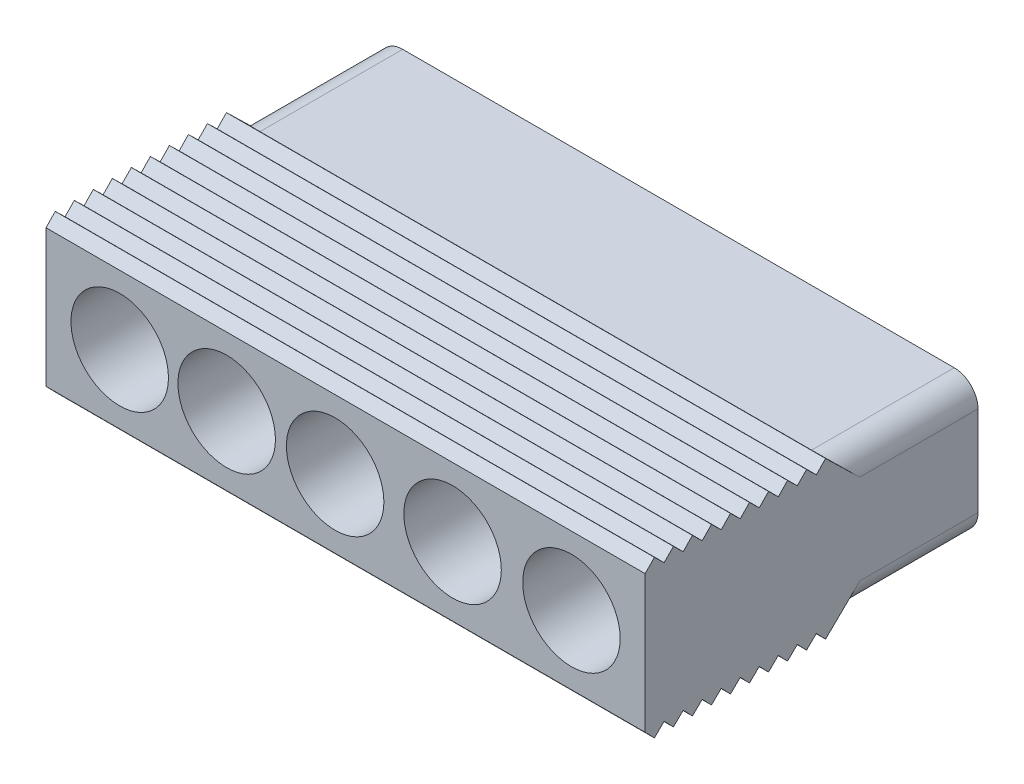
from build123d import *

# Parameters (mm, degrees)
SKETCH1_W            = 25.2
SKETCH1_H            = 5.78
BOSS_EXTRUDE1_DEPTH  = 14
SKETCH2_R            = 2.05
CUT_EXTRUDE1_DEPTH   = 13.1
CUT_EXTRUDE2_REACH   = 16
SKETCH4_R            = 1.775
BOSS_EXTRUDE2_DEPTH  = 0.3
BOSS_EXTRUDE3_DEPTH  = 25.2
LPATTERN1_COUNT      = 10
LPATTERN1_PITCH      = 0.8
MIRROR1_COPY_1_DEPTH = 25.2
MIRROR1_COPY_2_DEPTH = 25.2
MIRROR1_COPY_3_DEPTH = 25.2
MIRROR1_COPY_4_DEPTH = 25.2
MIRROR1_COPY_5_DEPTH = 25.2
MIRROR1_COPY_6_DEPTH = 25.2
MIRROR1_COPY_7_DEPTH = 25.2
MIRROR1_COPY_8_DEPTH = 25.2
MIRROR1_COPY_9_DEPTH = 25.2
FILLET1_R            = 1


with BuildPart() as part:
    # Sketch1 → Boss-Extrude1 (new body)
    with BuildSketch(Plane.XY):
        with Locations((-2.28, 0.689500873)):
            Rectangle(SKETCH1_W, SKETCH1_H)
    extrude(amount=BOSS_EXTRUDE1_DEPTH)

    # Sketch2 → Cut-Extrude1 (cut)
    with BuildSketch(Plane.XY.offset(14)):
        with Locations((-11.78, 0.689500873)):
            Circle(SKETCH2_R)
        with Locations((-7.28, 0.689500873)):
            Circle(SKETCH2_R)
        with Locations((-2.71821789, 0.689500873)):
            Circle(SKETCH2_R)
        with Locations((2.22, 0.689500873)):
            Circle(SKETCH2_R)
        with Locations((7.22, 0.689500873)):
            Circle(SKETCH2_R)
    extrude(amount=-CUT_EXTRUDE1_DEPTH, mode=Mode.SUBTRACT)

    # Sketch4 → Cut-Extrude2 (cut, up to next)
    with BuildSketch(Plane.XY.offset(14), mode=Mode.PRIVATE) as cut_extrude2_sk1:
        with Locations((7.22, 0.689500873)):
            Circle(SKETCH4_R)
    cut_extrude2_tool1 = extrude(cut_extrude2_sk1.sketch, amount=-CUT_EXTRUDE2_REACH, mode=Mode.PRIVATE) & part.part
    add(cut_extrude2_tool1.solids().sort_by_distance((7.22, 0.689501, 14))[0], mode=Mode.SUBTRACT)
    # Sketch4 → Cut-Extrude2 (cut, up to next)
    with BuildSketch(Plane.XY.offset(14), mode=Mode.PRIVATE) as cut_extrude2_sk2:
        with Locations((2.22, 0.689500873)):
            Circle(SKETCH4_R)
    cut_extrude2_tool2 = extrude(cut_extrude2_sk2.sketch, amount=-CUT_EXTRUDE2_REACH, mode=Mode.PRIVATE) & part.part
    add(cut_extrude2_tool2.solids().sort_by_distance((2.22, 0.689501, 14))[0], mode=Mode.SUBTRACT)
    # Sketch4 → Cut-Extrude2 (cut, up to next)
    with BuildSketch(Plane.XY.offset(14), mode=Mode.PRIVATE) as cut_extrude2_sk3:
        with Locations((-2.71821789, 0.689500873)):
            Circle(SKETCH4_R)
    cut_extrude2_tool3 = extrude(cut_extrude2_sk3.sketch, amount=-CUT_EXTRUDE2_REACH, mode=Mode.PRIVATE) & part.part
    add(cut_extrude2_tool3.solids().sort_by_distance((-2.718218, 0.689501, 14))[0], mode=Mode.SUBTRACT)
    # Sketch4 → Cut-Extrude2 (cut, up to next)
    with BuildSketch(Plane.XY.offset(14), mode=Mode.PRIVATE) as cut_extrude2_sk4:
        with Locations((-7.28, 0.689500873)):
            Circle(SKETCH4_R)
    cut_extrude2_tool4 = extrude(cut_extrude2_sk4.sketch, amount=-CUT_EXTRUDE2_REACH, mode=Mode.PRIVATE) & part.part
    add(cut_extrude2_tool4.solids().sort_by_distance((-7.28, 0.689501, 14))[0], mode=Mode.SUBTRACT)
    # Sketch4 → Cut-Extrude2 (cut, up to next)
    with BuildSketch(Plane.XY.offset(14), mode=Mode.PRIVATE) as cut_extrude2_sk5:
        with Locations((-11.78, 0.689500873)):
            Circle(SKETCH4_R)
    cut_extrude2_tool5 = extrude(cut_extrude2_sk5.sketch, amount=-CUT_EXTRUDE2_REACH, mode=Mode.PRIVATE) & part.part
    add(cut_extrude2_tool5.solids().sort_by_distance((-11.78, 0.689501, 14))[0], mode=Mode.SUBTRACT)

    # Sketch5 → Boss-Extrude2 (add)
    with BuildSketch(Plane.XZ.offset(2.200499127)):
        Polygon((5.565344548, 5.115989136), (6.350966069, 5.115989136), (6.675864556, 4.226955746), (8.154499953, 4.226955746), (8.479398441, 5.115989136), (9.269650344, 5.115989136), (7.813395128, 1.263511109), (7.028545337, 1.263511109), align=None)
        Polygon((6.91124232, 3.584876074), (7.417497446, 2.201935244), (7.922209111, 3.584876074), align=None, mode=Mode.SUBTRACT)
        with BuildLine():
            Line((3.948610508, 1.263511109), (2.396660726, 1.263511109))
            add(Edge.make_bspline(
                [(2.396660726, 1.263511109), (2.359360489, 1.263729429), (2.287329461, 1.264151031), (2.182869204, 1.265393936), (2.085894226, 1.268736074), (1.996082295, 1.272305516), (1.913726837, 1.277578451), (1.838624432, 1.284664747), (1.770950602, 1.292313344), (1.690889796, 1.302991783), (1.598490479, 1.32403547), (1.493642217, 1.358610026), (1.39493855, 1.403888217), (1.301805377, 1.458499444), (1.215843087, 1.524426943), (1.137736598, 1.600819207), (1.065966282, 1.68620286), (1.003197045, 1.781249302), (0.950716627, 1.884651514), (0.91416523, 1.995502844), (0.890657802, 2.112203236), (0.887828684, 2.192044487), (0.886384384, 2.232804459)],
                knots=[0, 0, 0, 0, 0.000111904, 0.000216099, 0.000313386, 0.000402989, 0.000485741, 0.00056092, 0.00062927, 0.00069006, 0.000803147, 0.000912966, 0.001020713, 0.001128316, 0.00123621, 0.001344816, 0.001455483, 0.001570209, 0.001685827, 0.001802235, 0.001919381, 0.002041558, 0.002041558, 0.002041558, 0.002041558], degree=3))
            add(Edge.make_bspline(
                [(0.886384384, 2.232804459), (0.887809836, 2.277208782), (0.890630305, 2.36506929), (0.919383734, 2.493104477), (0.962229037, 2.616216273), (1.024423896, 2.731017678), (1.100162495, 2.837171215), (1.190790518, 2.929188126), (1.292463211, 3.009404764), (1.369247746, 3.048712406), (1.408074117, 3.068588454)],
                knots=[0, 0, 0, 0, 0.000133009, 0.000263178, 0.000391816, 0.00052301, 0.000653453, 0.000781702, 0.000909358, 0.001039933, 0.001039933, 0.001039933, 0.001039933], degree=3))
            add(Edge.make_bspline(
                [(1.408074117, 3.068588454), (1.381956565, 3.077484352), (1.330315447, 3.09507383), (1.256399133, 3.127373139), (1.187143549, 3.164830538), (1.122583472, 3.206264872), (1.062228915, 3.25197904), (1.007843199, 3.303488816), (0.956305643, 3.357863665), (0.911059666, 3.417833045), (0.870105113, 3.480528711), (0.835340819, 3.546931978), (0.805237834, 3.615445677), (0.780062151, 3.686763213), (0.762116284, 3.761362908), (0.747736937, 3.838305), (0.740380865, 3.91812275), (0.738940991, 3.97201565), (0.738212152, 3.999295285)],
                knots=[0, 0, 0, 0, 8.2748e-05, 0.000163614, 0.000241651, 0.000318716, 0.000393577, 0.000468387, 0.000543198, 0.000618059, 0.000693409, 0.000767632, 0.000842621, 0.000917792, 0.000994158, 0.001072571, 0.001152433, 0.001234295, 0.001234295, 0.001234295, 0.001234295], degree=3))
            add(Edge.make_bspline(
                [(0.738212152, 3.999295285), (0.73976637, 4.042860457), (0.742876676, 4.130043209), (0.765972078, 4.259625684), (0.804159522, 4.387219209), (0.857218311, 4.511066905), (0.922592861, 4.628646918), (1.000900249, 4.734738507), (1.089727441, 4.828747927), (1.19010147, 4.909568329), (1.302486516, 4.977663389), (1.427549661, 5.030526219), (1.564651545, 5.069882807), (1.660965442, 5.082994391), (1.710592423, 5.089750304)],
                knots=[0, 0, 0, 0, 0.000130651, 0.000261458, 0.00039355, 0.000529439, 0.000664888, 0.000796241, 0.000923975, 0.001051852, 0.001181689, 0.001316867, 0.001458067, 0.001608158, 0.001608158, 0.001608158, 0.001608158], degree=3))
            add(Edge.make_bspline(
                [(1.710592423, 5.089750304), (1.729623612, 5.091355687), (1.773311169, 5.095040968), (1.847402837, 5.099622774), (1.938502217, 5.103086109), (2.046530205, 5.107181064), (2.17181936, 5.110137741), (2.314084936, 5.112156752), (2.473569675, 5.11477703), (2.585476304, 5.115571115), (2.644386176, 5.115989136)],
                knots=[0, 0, 0, 0, 5.7295e-05, 0.000131526, 0.000222672, 0.000330783, 0.000455842, 0.00059863, 0.000757624, 0.000934357, 0.000934357, 0.000934357, 0.000934357], degree=3))
            Line((2.644386176, 5.115989136), (3.948610508, 5.115989136))
            Line((3.948610508, 5.115989136), (3.948610508, 1.263511109))
        make_face()
        with BuildLine():
            Line((3.207749349, 1.90559078), (3.207749349, 2.794624171))
            Line((3.207749349, 2.794624171), (2.671396739, 2.794624171))
            add(Edge.make_bspline(
                [(2.671396739, 2.794624171), (2.633581615, 2.794707482), (2.561551841, 2.794866171), (2.459171167, 2.793802767), (2.367843704, 2.793306322), (2.287832021, 2.791849334), (2.219152544, 2.789444763), (2.162052736, 2.787043604), (2.116202639, 2.785225649), (2.089505192, 2.782629691), (2.077936081, 2.781504755)],
                knots=[0, 0, 0, 0, 0.000113444, 0.000216087, 0.000307155, 0.00038743, 0.000456153, 0.000513308, 0.000558899, 0.000593763, 0.000593763, 0.000593763, 0.000593763], degree=3))
            add(Edge.make_bspline(
                [(2.077936081, 2.781504755), (2.04456019, 2.776503765), (1.980413775, 2.766892169), (1.890630004, 2.738291447), (1.811915304, 2.698052123), (1.745939077, 2.645887945), (1.691883166, 2.584536341), (1.654412919, 2.512195576), (1.631337039, 2.430993955), (1.6286434, 2.373677738), (1.627245543, 2.343933633)],
                knots=[0, 0, 0, 0, 0.000101123, 0.000194353, 0.000281336, 0.000364861, 0.000445303, 0.000524701, 0.00060728, 0.000696364, 0.000696364, 0.000696364, 0.000696364], degree=3))
            add(Edge.make_bspline(
                [(1.627245543, 2.343933633), (1.628182941, 2.315492455), (1.629998532, 2.260406403), (1.650981242, 2.18264882), (1.682772835, 2.112403946), (1.72902174, 2.051384951), (1.788784728, 2.000877344), (1.86067227, 1.960703649), (1.945473503, 1.93335539), (2.006502575, 1.923755594), (2.038577832, 1.918710197)],
                knots=[0, 0, 0, 0, 8.5115e-05, 0.000164853, 0.000239775, 0.000315251, 0.000392428, 0.000472932, 0.000560787, 0.000658114, 0.000658114, 0.000658114, 0.000658114], degree=3))
            add(Edge.make_bspline(
                [(2.038577832, 1.918710197), (2.05117635, 1.917581798), (2.080961504, 1.914914061), (2.132728511, 1.913181302), (2.198829789, 1.910723547), (2.279088615, 1.908382815), (2.373760856, 1.906891819), (2.482323129, 1.906416201), (2.605283506, 1.905343918), (2.69197592, 1.905505457), (2.737765551, 1.90559078)],
                knots=[0, 0, 0, 0, 3.7941e-05, 8.9698e-05, 0.000155336, 0.000236401, 0.000330565, 0.000439381, 0.000562089, 0.000699457, 0.000699457, 0.000699457, 0.000699457], degree=3))
            Line((2.737765551, 1.90559078), (3.207749349, 1.90559078))
        make_face(mode=Mode.SUBTRACT)
        with BuildLine():
            Line((3.207749349, 3.436703843), (3.207749349, 4.473909465))
            Line((3.207749349, 4.473909465), (2.451453582, 4.473909465))
            add(Edge.make_bspline(
                [(2.451453582, 4.473909465), (2.416209482, 4.474084294), (2.349318686, 4.474416107), (2.253894747, 4.472193667), (2.168709758, 4.471460847), (2.093365018, 4.467804767), (2.028256448, 4.46503898), (1.973116145, 4.461590963), (1.928374646, 4.45610762), (1.901971605, 4.451850625), (1.8904056, 4.449985824)],
                knots=[0, 0, 0, 0, 0.000105727, 0.000200662, 0.000286338, 0.00036126, 0.00042693, 0.000481858, 0.000526943, 0.000562089, 0.000562089, 0.000562089, 0.000562089], degree=3))
            add(Edge.make_bspline(
                [(1.8904056, 4.449985824), (1.861032664, 4.443789315), (1.803963338, 4.431749982), (1.724886025, 4.397188911), (1.653228117, 4.353218007), (1.591665084, 4.296574571), (1.539922296, 4.22972946), (1.504717678, 4.15059231), (1.48228265, 4.061754423), (1.48017452, 3.998928693), (1.479073311, 3.966110879)],
                knots=[0, 0, 0, 0, 8.9843e-05, 0.000174558, 0.000257424, 0.000341003, 0.000424196, 0.000509143, 0.000598985, 0.000697241, 0.000697241, 0.000697241, 0.000697241], degree=3))
            add(Edge.make_bspline(
                [(1.479073311, 3.966110879), (1.479952853, 3.937967908), (1.481664778, 3.883190901), (1.499485919, 3.804771406), (1.526105069, 3.73239646), (1.565263414, 3.667581003), (1.615417361, 3.611002612), (1.674726942, 3.561548533), (1.744534251, 3.521388895), (1.810953977, 3.494767709), (1.873882172, 3.477313392), (1.93450193, 3.467565061), (2.006954879, 3.457033596), (2.091757251, 3.45009901), (2.188468264, 3.443545881), (2.297357448, 3.440494331), (2.418502378, 3.436767827), (2.503412768, 3.436725847), (2.547919879, 3.436703843)],
                knots=[0, 0, 0, 0, 8.4292e-05, 0.000164064, 0.000240028, 0.000314806, 0.000389728, 0.00046591, 0.000545458, 0.000630296, 0.000679909, 0.000741066, 0.000814299, 0.00089954, 0.000996204, 0.001105086, 0.001226287, 0.001359798, 0.001359798, 0.001359798, 0.001359798], degree=3))
            Line((2.547919879, 3.436703843), (3.207749349, 3.436703843))
        make_face(mode=Mode.SUBTRACT)
        with BuildLine():
            add(Edge.make_bspline(
                [(-2.557807182, 1.263511109), (-2.603666, 1.264613532), (-2.692947863, 1.266759824), (-2.823016429, 1.285884832), (-2.945342558, 1.31623148), (-3.05994986, 1.360066798), (-3.167421192, 1.415546055), (-3.266244385, 1.485133496), (-3.358707652, 1.565450648), (-3.412086175, 1.62781847), (-3.439123269, 1.659408791)],
                knots=[0, 0, 0, 0, 0.000137507, 0.00026771, 0.00039349, 0.000514887, 0.00063501, 0.000755323, 0.000876708, 0.001001299, 0.001001299, 0.001001299, 0.001001299], degree=3))
            add(Edge.make_bspline(
                [(-3.439123269, 1.659408791), (-3.454589811, 1.679525698), (-3.486154311, 1.720580781), (-3.528664115, 1.786921385), (-3.569533533, 1.857293606), (-3.605200709, 1.933393914), (-3.639385147, 2.013891557), (-3.67093989, 2.099010374), (-3.698802412, 2.189231362), (-3.723091615, 2.284143714), (-3.745796182, 2.383891693), (-3.764816749, 2.488718553), (-3.781095108, 2.598359149), (-3.793789925, 2.712693849), (-3.805171682, 2.83149858), (-3.811399528, 2.955354476), (-3.816502099, 3.083980963), (-3.817011852, 3.17148002), (-3.817271153, 3.215988956)],
                knots=[0, 0, 0, 0, 7.6093e-05, 0.000155292, 0.000236177, 0.000320054, 0.000407202, 0.00049852, 0.000592253, 0.000690336, 0.000792374, 0.000899087, 0.001009865, 0.001124832, 0.001244169, 0.001367841, 0.001496803, 0.001630321, 0.001630321, 0.001630321, 0.001630321], degree=3))
            add(Edge.make_bspline(
                [(-3.817271153, 3.215988956), (-3.817015759, 3.260497993), (-3.816515161, 3.347740158), (-3.811380513, 3.476108596), (-3.805166128, 3.599706258), (-3.79381645, 3.718517335), (-3.780999738, 3.832829308), (-3.765183218, 3.942347019), (-3.744693844, 4.046692215), (-3.722323839, 4.146281169), (-3.698189378, 4.241596708), (-3.669088439, 4.331654817), (-3.638806412, 4.417834504), (-3.603827469, 4.498435704), (-3.566880381, 4.574630199), (-3.526619135, 4.645720718), (-3.483634671, 4.712472464), (-3.451764804, 4.753744135), (-3.436036348, 4.774112581)],
                knots=[0, 0, 0, 0, 0.000133518, 0.000261709, 0.000385381, 0.000504718, 0.000619685, 0.000730462, 0.000836561, 0.000938598, 0.001036681, 0.001131381, 0.001222435, 0.001310595, 0.001394809, 0.001476365, 0.001555564, 0.001632737, 0.001632737, 0.001632737, 0.001632737], degree=3))
            add(Edge.make_bspline(
                [(-3.436036348, 4.774112581), (-3.4092466, 4.805432108), (-3.356362344, 4.867258368), (-3.264922795, 4.946909793), (-3.166259154, 5.015060201), (-3.058982421, 5.069428445), (-2.944932997, 5.113558155), (-2.822407593, 5.142931254), (-2.692694388, 5.16209532), (-2.603410909, 5.16426941), (-2.557807182, 5.16537988)],
                knots=[0, 0, 0, 0, 0.000123501, 0.000243797, 0.000362598, 0.000482366, 0.000603763, 0.000728607, 0.000859574, 0.00099631, 0.00099631, 0.00099631, 0.00099631], degree=3))
            add(Edge.make_bspline(
                [(-2.557807182, 5.16537988), (-2.511683485, 5.164053021), (-2.421301709, 5.161452971), (-2.289344301, 5.140831941), (-2.16389784, 5.107821351), (-2.045482674, 5.060605661), (-1.933879619, 4.999653055), (-1.829342826, 4.925428874), (-1.732609755, 4.836849559), (-1.657022732, 4.754263044), (-1.602108183, 4.679685318), (-1.562390558, 4.618260247), (-1.525462554, 4.551612548), (-1.492649436, 4.478912198), (-1.460620011, 4.402007148), (-1.432358582, 4.319438976), (-1.40702531, 4.231785712), (-1.383540093, 4.138973659), (-1.364093055, 4.040454778), (-1.346016597, 3.937089015), (-1.331666761, 3.828397449), (-1.319132387, 3.714698301), (-1.310240296, 3.595503164), (-1.30303377, 3.471250362), (-1.299417154, 3.341545055), (-1.298705985, 3.253290939), (-1.298343212, 3.208271652)],
                knots=[0, 0, 0, 0, 0.000138314, 0.000271034, 0.000399638, 0.000526751, 0.000652458, 0.000780297, 0.000910338, 0.001045311, 0.001115386, 0.001187953, 0.001264635, 0.001343706, 0.001427113, 0.001514486, 0.001605334, 0.001700792, 0.001801591, 0.001906515, 0.002015548, 0.002130429, 0.002249636, 0.002374079, 0.002503787, 0.002638848, 0.002638848, 0.002638848, 0.002638848], degree=3))
            add(Edge.make_bspline(
                [(-1.298343212, 3.208271652), (-1.298596684, 3.16401971), (-1.299093456, 3.077291591), (-1.304263881, 2.94943974), (-1.310402089, 2.826350978), (-1.321854018, 2.707805852), (-1.334565288, 2.593999225), (-1.350409071, 2.48473099), (-1.371282103, 2.380797037), (-1.391889282, 2.281042286), (-1.417854835, 2.186443465), (-1.446460668, 2.096453073), (-1.476642284, 2.010466078), (-1.511978302, 1.930281651), (-1.54871151, 1.854250849), (-1.589000955, 1.783172804), (-1.631978321, 1.716417919), (-1.663849107, 1.675146654), (-1.679578016, 1.654778409)],
                knots=[0, 0, 0, 0, 0.000132747, 0.000260166, 0.000383838, 0.000502406, 0.000617373, 0.000727388, 0.000833486, 0.000935357, 0.001032892, 0.001127592, 0.001218646, 0.001306097, 0.001390311, 0.001471867, 0.001551066, 0.001628239, 0.001628239, 0.001628239, 0.001628239], degree=3))
            add(Edge.make_bspline(
                [(-1.679578016, 1.654778409), (-1.706369238, 1.623461894), (-1.759256402, 1.561641582), (-1.850674659, 1.48194662), (-1.949229338, 1.414089114), (-2.056193035, 1.359062224), (-2.170504508, 1.31552933), (-2.29319047, 1.285919954), (-2.422924346, 1.266806334), (-2.512204933, 1.264625185), (-2.557807182, 1.263511109)],
                knots=[0, 0, 0, 0, 0.000123501, 0.000243797, 0.000362598, 0.00048168, 0.000603799, 0.000728643, 0.00085961, 0.000996346, 0.000996346, 0.000996346, 0.000996346], degree=3))
        make_face()
        with BuildLine():
            add(Edge.make_bspline(
                [(-2.557807182, 1.90559078), (-2.534045228, 1.906612668), (-2.487543991, 1.908612463), (-2.419913986, 1.924919457), (-2.356035774, 1.950178205), (-2.296098766, 1.987273438), (-2.24059005, 2.037500592), (-2.193559469, 2.105369654), (-2.152902327, 2.188562204), (-2.13256275, 2.250762538), (-2.121779521, 2.283738664)],
                knots=[0, 0, 0, 0, 7.1204e-05, 0.000139344, 0.000207558, 0.000276519, 0.000349716, 0.000430457, 0.000522607, 0.000626587, 0.000626587, 0.000626587, 0.000626587], degree=3))
            add(Edge.make_bspline(
                [(-2.121779521, 2.283738664), (-2.115044271, 2.308618851), (-2.100568437, 2.36209296), (-2.084147231, 2.449278843), (-2.070531018, 2.548474985), (-2.059250552, 2.659174163), (-2.049794706, 2.781641102), (-2.044120841, 2.915743142), (-2.040143578, 3.061876385), (-2.039525772, 3.163250952), (-2.039204371, 3.215988956)],
                knots=[0, 0, 0, 0, 7.7304e-05, 0.000166147, 0.0002659, 0.000377631, 0.000499915, 0.000634338, 0.000780246, 0.000938459, 0.000938459, 0.000938459, 0.000938459], degree=3))
            add(Edge.make_bspline(
                [(-2.039204371, 3.215988956), (-2.03916949, 3.268471461), (-2.039102625, 3.369079546), (-2.043628343, 3.513383009), (-2.048119258, 3.644936659), (-2.05726971, 3.76373257), (-2.0661883, 3.86995224), (-2.079966489, 3.962985211), (-2.093558792, 4.043684556), (-2.116930808, 4.131080929), (-2.148738875, 4.222969076), (-2.191866451, 4.31633061), (-2.241169316, 4.389226095), (-2.296838245, 4.442723965), (-2.357745222, 4.477805268), (-2.420159748, 4.505738573), (-2.488004324, 4.519742831), (-2.534349517, 4.522104731), (-2.557807182, 4.523300209)],
                knots=[0, 0, 0, 0, 0.000157435, 0.0003018, 0.000433105, 0.000552255, 0.000659225, 0.000752757, 0.000834346, 0.000904539, 0.001023888, 0.001125716, 0.001212205, 0.001286451, 0.001355009, 0.001422092, 0.001490815, 0.00156125, 0.00156125, 0.00156125, 0.00156125], degree=3))
            add(Edge.make_bspline(
                [(-2.557807182, 4.523300209), (-2.58129897, 4.522223724), (-2.627767871, 4.520094337), (-2.695309386, 4.504313511), (-2.759096776, 4.478271709), (-2.819437538, 4.441917691), (-2.874998294, 4.391344249), (-2.922063232, 4.323536121), (-2.962709509, 4.240324302), (-2.983050739, 4.178126898), (-2.993834844, 4.145152326)],
                knots=[0, 0, 0, 0, 7.0435e-05, 0.000139327, 0.000206826, 0.000276444, 0.000349641, 0.000430381, 0.000522531, 0.000626512, 0.000626512, 0.000626512, 0.000626512], degree=3))
            add(Edge.make_bspline(
                [(-2.993834844, 4.145152326), (-3.00055996, 4.120270125), (-3.014948127, 4.067035473), (-3.031493712, 3.980393068), (-3.045078651, 3.881959878), (-3.056410016, 3.771779685), (-3.06581145, 3.649564215), (-3.071496114, 3.5154633), (-3.075462617, 3.369586873), (-3.076086298, 3.268469662), (-3.076409994, 3.215988956)],
                knots=[0, 0, 0, 0, 7.7304e-05, 0.00016539, 0.000264379, 0.000375342, 0.000497626, 0.000632049, 0.000777957, 0.000935398, 0.000935398, 0.000935398, 0.000935398], degree=3))
            add(Edge.make_bspline(
                [(-3.076409994, 3.215988956), (-3.07597201, 3.163511861), (-3.07513247, 3.062922071), (-3.072712978, 2.918289086), (-3.065966804, 2.786605849), (-3.059139592, 2.667355599), (-3.047818128, 2.561165693), (-3.036427707, 2.467493393), (-3.020727819, 2.386979319), (-2.999310037, 2.299402761), (-2.966896421, 2.207756406), (-2.922509281, 2.115237478), (-2.87457703, 2.040975331), (-2.81869327, 1.987213267), (-2.758138448, 1.950471218), (-2.694756445, 1.924733368), (-2.627533888, 1.90870883), (-2.581304628, 1.906641543), (-2.557807182, 1.90559078)],
                knots=[0, 0, 0, 0, 0.000157441, 0.000301787, 0.000433897, 0.000552994, 0.00066004, 0.000754232, 0.000835962, 0.000905965, 0.001024586, 0.001126749, 0.001213437, 0.001288215, 0.001357176, 0.001424675, 0.001492815, 0.00156325, 0.00156325, 0.00156325, 0.00156325], degree=3))
        make_face(mode=Mode.SUBTRACT)
        with BuildLine():
            Line((-7.675191481, 5.115989136), (-6.934330322, 5.115989136))
            Line((-6.934330322, 5.115989136), (-6.934330322, 2.373259387))
            add(Edge.make_bspline(
                [(-6.934330322, 2.373259387), (-6.900794167, 2.407398394), (-6.834041921, 2.47535059), (-6.726852895, 2.569058935), (-6.616606429, 2.657537376), (-6.501583868, 2.738764669), (-6.381353917, 2.812095253), (-6.257030618, 2.878954938), (-6.129070109, 2.94091048), (-6.040412994, 2.975049167), (-5.995906187, 2.992187147)],
                knots=[0, 0, 0, 0, 0.000143519, 0.000285668, 0.000426802, 0.000567473, 0.000707771, 0.000849, 0.000990875, 0.001133895, 0.001133895, 0.001133895, 0.001133895], degree=3))
            Line((-5.995906187, 2.992187147), (-5.995906187, 2.251325988))
            add(Edge.make_bspline(
                [(-5.995906187, 2.251325988), (-6.045249464, 2.232832865), (-6.148521103, 2.194128196), (-6.301022555, 2.111546615), (-6.460553696, 2.009964217), (-6.594404958, 1.91016532), (-6.699678291, 1.820609418), (-6.773807017, 1.749419775), (-6.842473167, 1.676190393), (-6.903152659, 1.598927319), (-6.957386594, 1.519132718), (-7.005442744, 1.436952589), (-7.047742547, 1.352123252), (-7.069886297, 1.293050129), (-7.080959093, 1.263511109)],
                knots=[0, 0, 0, 0, 0.000157924, 0.000330523, 0.000518921, 0.000725128, 0.000830765, 0.000933379, 0.001033314, 0.001131664, 0.001227771, 0.00132254, 0.001417108, 0.001511691, 0.001511691, 0.001511691, 0.001511691], degree=3))
            Line((-7.080959093, 1.263511109), (-7.675191481, 1.263511109))
            Line((-7.675191481, 1.263511109), (-7.675191481, 5.115989136))
        make_face()
        with BuildLine():
            Line((-12.817271153, 4.375127977), (-12.817271153, 5.115989136))
            Line((-12.817271153, 5.115989136), (-10.298343212, 5.115989136))
            add(Edge.make_bspline(
                [(-10.298343212, 5.115989136), (-10.306888227, 5.052677425), (-10.323973467, 4.926089501), (-10.376470817, 4.740984462), (-10.447835268, 4.560766707), (-10.524526194, 4.414257727), (-10.599082582, 4.295108645), (-10.669286734, 4.199352759), (-10.749991016, 4.095388403), (-10.845385198, 3.986415252), (-10.950301459, 3.868107827), (-11.068999182, 3.743836998), (-11.200121558, 3.613033018), (-11.292442145, 3.52427317), (-11.340179217, 3.478377283)],
                knots=[0, 0, 0, 0, 0.000191454, 0.000382802, 0.000575407, 0.00077216, 0.000877932, 0.000996801, 0.001128179, 0.001272656, 0.001431148, 0.001602552, 0.001788089, 0.001986749, 0.001986749, 0.001986749, 0.001986749], degree=3))
            add(Edge.make_bspline(
                [(-11.340179217, 3.478377283), (-11.378269117, 3.441610744), (-11.450781068, 3.371618083), (-11.554033021, 3.271386474), (-11.644564505, 3.179521245), (-11.724709139, 3.097820914), (-11.792513649, 3.024610413), (-11.848947547, 2.960616286), (-11.894317423, 2.906194799), (-11.918888576, 2.871668477), (-11.929781222, 2.856362601)],
                knots=[0, 0, 0, 0, 0.000158821, 0.000302348, 0.000431679, 0.000545741, 0.000645677, 0.00073098, 0.000801731, 0.000858073, 0.000858073, 0.000858073, 0.000858073], degree=3))
            add(Edge.make_bspline(
                [(-11.929781222, 2.856362601), (-11.952198376, 2.819352303), (-11.995387496, 2.748047881), (-12.041074307, 2.63514364), (-12.070892747, 2.523231868), (-12.07459173, 2.448036861), (-12.076409994, 2.411074175)],
                knots=[0, 0, 0, 0, 0.000129607, 0.000249702, 0.000364252, 0.000474997, 0.000474997, 0.000474997, 0.000474997], degree=3))
            add(Edge.make_bspline(
                [(-12.076409994, 2.411074175), (-12.075061548, 2.372618829), (-12.072510394, 2.299864314), (-12.049974056, 2.197337067), (-12.01252442, 2.108248477), (-11.95825348, 2.034340145), (-11.890528996, 1.975767229), (-11.810112906, 1.934441845), (-11.718161881, 1.910237392), (-11.653395318, 1.907185714), (-11.619545612, 1.90559078)],
                knots=[0, 0, 0, 0, 0.000115247, 0.000218037, 0.000313089, 0.000403077, 0.000490634, 0.000579343, 0.000672005, 0.000773457, 0.000773457, 0.000773457, 0.000773457], degree=3))
            add(Edge.make_bspline(
                [(-11.619545612, 1.90559078), (-11.585946657, 1.907117118), (-11.521040731, 1.910065672), (-11.428742034, 1.935703765), (-11.348345734, 1.980287941), (-11.290434286, 2.030217729), (-11.251473632, 2.07954211), (-11.225459533, 2.123021974), (-11.202368716, 2.171918181), (-11.182202769, 2.226058127), (-11.166216268, 2.286081935), (-11.153359162, 2.351585395), (-11.142992991, 2.4229052), (-11.139697008, 2.47252104), (-11.137985859, 2.498279708)],
                knots=[0, 0, 0, 0, 0.000100683, 0.000194499, 0.000284298, 0.000374538, 0.000421784, 0.000472343, 0.000526193, 0.00058382, 0.000645413, 0.00071231, 0.000784014, 0.000861434, 0.000861434, 0.000861434, 0.000861434], degree=3))
            Line((-11.137985859, 2.498279708), (-10.3971247, 2.425737052))
            add(Edge.make_bspline(
                [(-10.3971247, 2.425737052), (-10.403081007, 2.375719499), (-10.414629336, 2.278743455), (-10.443450251, 2.139453845), (-10.479944363, 2.0109477), (-10.525878894, 1.893486891), (-10.579262124, 1.786243661), (-10.643256185, 1.690944193), (-10.714417496, 1.605738067), (-10.794564299, 1.532221996), (-10.881622525, 1.469044524), (-10.973790641, 1.413913431), (-11.071290804, 1.367610432), (-11.174138615, 1.329691678), (-11.281908528, 1.299310034), (-11.395170222, 1.279240839), (-11.51320493, 1.265118666), (-11.593776676, 1.264055038), (-11.63498022, 1.263511109)],
                knots=[0, 0, 0, 0, 0.000151054, 0.00029287, 0.000426225, 0.000551336, 0.000670753, 0.000784836, 0.000894912, 0.001003048, 0.001110171, 0.001217111, 0.001324811, 0.001433472, 0.001545628, 0.001660211, 0.001778245, 0.001901782, 0.001901782, 0.001901782, 0.001901782], degree=3))
            add(Edge.make_bspline(
                [(-11.63498022, 1.263511109), (-11.679773857, 1.264371823), (-11.767015091, 1.266048171), (-11.894369557, 1.279897274), (-12.014018301, 1.304030972), (-12.126968962, 1.336045591), (-12.232197334, 1.378623397), (-12.330152149, 1.430703656), (-12.420990664, 1.491677554), (-12.50315917, 1.562203141), (-12.577560298, 1.638697673), (-12.640411337, 1.722317882), (-12.69635221, 1.808433561), (-12.739992107, 1.900595432), (-12.775597729, 1.996442038), (-12.798496166, 2.097723748), (-12.815244063, 2.202924408), (-12.816587983, 2.274921765), (-12.817271153, 2.311520957)],
                knots=[0, 0, 0, 0, 0.000134361, 0.000261685, 0.000383672, 0.000500172, 0.000613386, 0.000723516, 0.000832464, 0.000940864, 0.001047843, 0.001151878, 0.001254216, 0.001355348, 0.001457149, 0.001560287, 0.001666371, 0.001776054, 0.001776054, 0.001776054, 0.001776054], degree=3))
            add(Edge.make_bspline(
                [(-12.817271153, 2.311520957), (-12.816326863, 2.353513922), (-12.814453536, 2.43682152), (-12.796576328, 2.559989346), (-12.76912878, 2.680260497), (-12.729033268, 2.798298142), (-12.676361151, 2.9156573), (-12.611880159, 3.035231227), (-12.533778622, 3.156917993), (-12.474351273, 3.236666778), (-12.443753652, 3.277727385)],
                knots=[0, 0, 0, 0, 0.000125908, 0.000249782, 0.000372584, 0.000495583, 0.00062307, 0.000758079, 0.000902796, 0.001056388, 0.001056388, 0.001056388, 0.001056388], degree=3))
            add(Edge.make_bspline(
                [(-12.443753652, 3.277727385), (-12.432046955, 3.292496062), (-12.406973925, 3.324127145), (-12.364189847, 3.372274359), (-12.315631353, 3.426082923), (-12.259071818, 3.48328444), (-12.196588516, 3.546350733), (-12.126525818, 3.612902448), (-12.049591561, 3.684121301), (-11.968877635, 3.758563514), (-11.887355343, 3.830769453), (-11.812824132, 3.899559709), (-11.746050013, 3.961400971), (-11.687676985, 4.017003651), (-11.636682045, 4.065298298), (-11.594031305, 4.107282573), (-11.559057004, 4.142340699), (-11.510653564, 4.197071797), (-11.449961827, 4.271439293), (-11.406399752, 4.341740582), (-11.385711309, 4.375127977)],
                knots=[0, 0, 0, 0, 5.6526e-05, 0.000121066, 0.000193172, 0.000273943, 0.000362345, 0.000459504, 0.000563802, 0.000676867, 0.000788896, 0.000890489, 0.000981134, 0.001061926, 0.00113234, 0.001191824, 0.001241485, 0.001280836, 0.001411002, 0.001528733, 0.001528733, 0.001528733, 0.001528733], degree=3))
            Line((-11.385711309, 4.375127977), (-12.817271153, 4.375127977))
        make_face()
    extrude(amount=BOSS_EXTRUDE2_DEPTH)

    # Sketch6 → Boss-Extrude3 (add)
    with BuildSketch(Plane(origin=(10.32, 0, 0), x_dir=(0, 0, -1), z_dir=(1, 0, 0))):
        Polygon((-14, -2.200499127), (-13.610583175, -2.600359098), (-13.2, -2.200499127), align=None)
    boss_extrude3 = extrude(amount=-BOSS_EXTRUDE3_DEPTH)

    # LPattern1: Boss-Extrude3 ×10
    with Locations(*[(0, 0, -i * LPATTERN1_PITCH) for i in range(1, LPATTERN1_COUNT)]):
        add(boss_extrude3)

    # Mirror1: Boss-Extrude3 across plane
    add(boss_extrude3.mirror(Plane(origin=(0, 0.689500873, 0), x_dir=(0, 0, 1), z_dir=(0, -1, 0))))

    # Mirror1 copy 1 sketch → Mirror1 copy 1 (add)
    with BuildSketch(Plane(origin=(10.32, 1.379001747, -0.8), x_dir=(0, 0, -1), z_dir=(1, 0, 0))):
        Polygon((-14, 2.200499127), (-13.610583175, 2.600359098), (-13.2, 2.200499127), align=None)
    extrude(amount=-MIRROR1_COPY_1_DEPTH)

    # Mirror1 copy 2 sketch → Mirror1 copy 2 (add)
    with BuildSketch(Plane(origin=(10.32, 1.379001747, -1.6), x_dir=(0, 0, -1), z_dir=(1, 0, 0))):
        Polygon((-14, 2.200499127), (-13.610583175, 2.600359098), (-13.2, 2.200499127), align=None)
    extrude(amount=-MIRROR1_COPY_2_DEPTH)

    # Mirror1 copy 3 sketch → Mirror1 copy 3 (add)
    with BuildSketch(Plane(origin=(10.32, 1.379001747, -2.4), x_dir=(0, 0, -1), z_dir=(1, 0, 0))):
        Polygon((-14, 2.200499127), (-13.610583175, 2.600359098), (-13.2, 2.200499127), align=None)
    extrude(amount=-MIRROR1_COPY_3_DEPTH)

    # Mirror1 copy 4 sketch → Mirror1 copy 4 (add)
    with BuildSketch(Plane(origin=(10.32, 1.379001747, -3.2), x_dir=(0, 0, -1), z_dir=(1, 0, 0))):
        Polygon((-14, 2.200499127), (-13.610583175, 2.600359098), (-13.2, 2.200499127), align=None)
    extrude(amount=-MIRROR1_COPY_4_DEPTH)

    # Mirror1 copy 5 sketch → Mirror1 copy 5 (add)
    with BuildSketch(Plane(origin=(10.32, 1.379001747, -4), x_dir=(0, 0, -1), z_dir=(1, 0, 0))):
        Polygon((-14, 2.200499127), (-13.610583175, 2.600359098), (-13.2, 2.200499127), align=None)
    extrude(amount=-MIRROR1_COPY_5_DEPTH)

    # Mirror1 copy 6 sketch → Mirror1 copy 6 (add)
    with BuildSketch(Plane(origin=(10.32, 1.379001747, -4.8), x_dir=(0, 0, -1), z_dir=(1, 0, 0))):
        Polygon((-14, 2.200499127), (-13.610583175, 2.600359098), (-13.2, 2.200499127), align=None)
    extrude(amount=-MIRROR1_COPY_6_DEPTH)

    # Mirror1 copy 7 sketch → Mirror1 copy 7 (add)
    with BuildSketch(Plane(origin=(10.32, 1.379001747, -5.6), x_dir=(0, 0, -1), z_dir=(1, 0, 0))):
        Polygon((-14, 2.200499127), (-13.610583175, 2.600359098), (-13.2, 2.200499127), align=None)
    extrude(amount=-MIRROR1_COPY_7_DEPTH)

    # Mirror1 copy 8 sketch → Mirror1 copy 8 (add)
    with BuildSketch(Plane(origin=(10.32, 1.379001747, -6.4), x_dir=(0, 0, -1), z_dir=(1, 0, 0))):
        Polygon((-14, 2.200499127), (-13.610583175, 2.600359098), (-13.2, 2.200499127), align=None)
    extrude(amount=-MIRROR1_COPY_8_DEPTH)

    # Mirror1 copy 9 sketch → Mirror1 copy 9 (add)
    with BuildSketch(Plane(origin=(10.32, 1.379001747, -7.2), x_dir=(0, 0, -1), z_dir=(1, 0, 0))):
        Polygon((-14, 2.200499127), (-13.610583175, 2.600359098), (-13.2, 2.200499127), align=None)
    extrude(amount=-MIRROR1_COPY_9_DEPTH)

    # Fillet1
    fillet1_edges = [part.edges().sort_by_distance(p)[0] for p in [
        (-14.88, -2.200499127, 3),
        (10.32, -2.200499127, 3),
        (-14.88, 3.579500873, 3),
        (10.32, 3.579500873, 3),
    ]]
    fillet(fillet1_edges, radius=FILLET1_R)


solid = part.part
